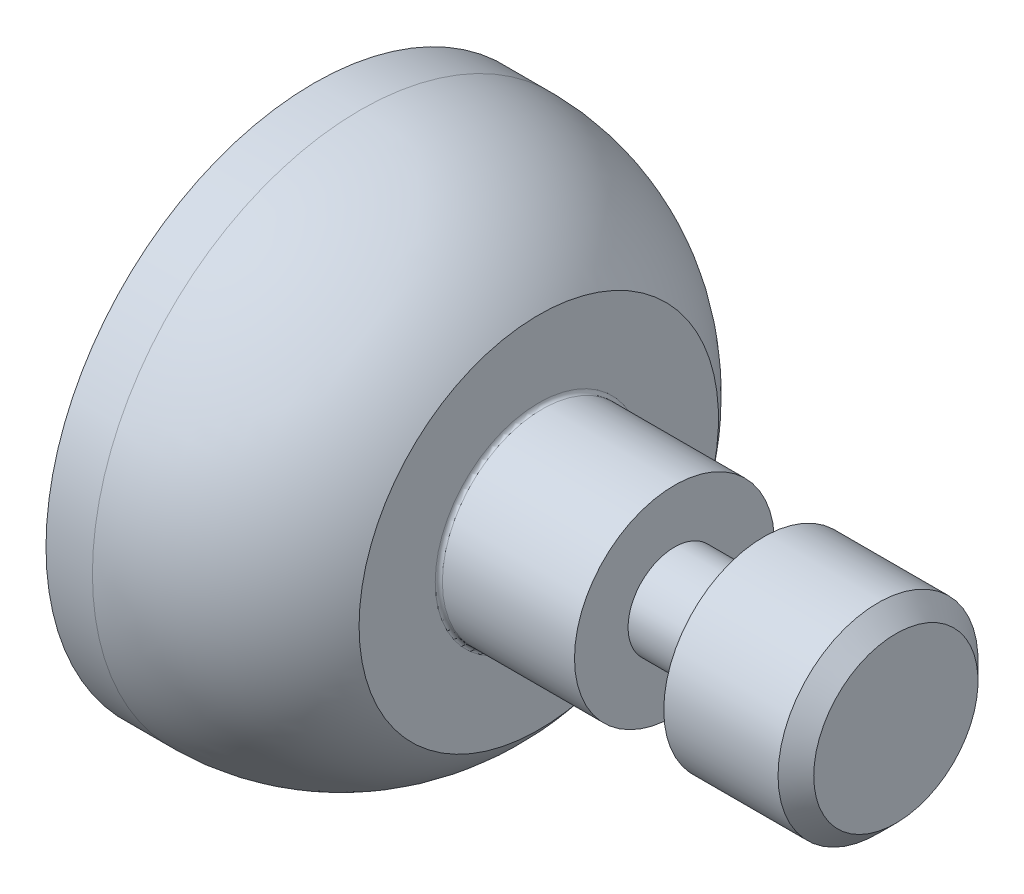
from build123d import *

# Parameters (mm, degrees)
FILLET1_R     = 0.01
CHAMFER1_SIZE = 0.05


with BuildPart() as part:
    # Sketch1 → Revolve1 (revolve)
    with BuildSketch(Plane.XY):
        with BuildLine():
            Line((0, 0), (0, 0.75))
            Line((0, 0.75), (0.13, 0.75))
            ThreePointArc((0.13, 0.75), (0.408779953, 0.684961714), (0.63, 0.503275358))
            Line((0.63, 0.503275358), (0.63, 0.28))
            Line((0.63, 0.28), (1.01, 0.28))
            Line((1.01, 0.28), (1.01, 0.13))
            Line((1.01, 0.13), (1.26, 0.13))
            Line((1.26, 0.13), (1.26, 0.28))
            Line((1.26, 0.28), (1.63, 0.28))
            Line((1.63, 0.28), (1.63, 0))
            Line((1.63, 0), (0, 0))
        make_face()
    revolve(axis=Axis((-1.695285667, 0, 0), (1, 0, 0)))

    # Fillet1
    fillet1_edges = [part.edges().sort_by_distance(p)[0] for p in [
        (0.63, -0.28, 0),
    ]]
    fillet(fillet1_edges, radius=FILLET1_R)

    # Chamfer1
    chamfer1_edges = [part.edges().sort_by_distance(p)[0] for p in [
        (1.63, -0.28, 0),
    ]]
    chamfer(chamfer1_edges, length=CHAMFER1_SIZE)


solid = part.part
